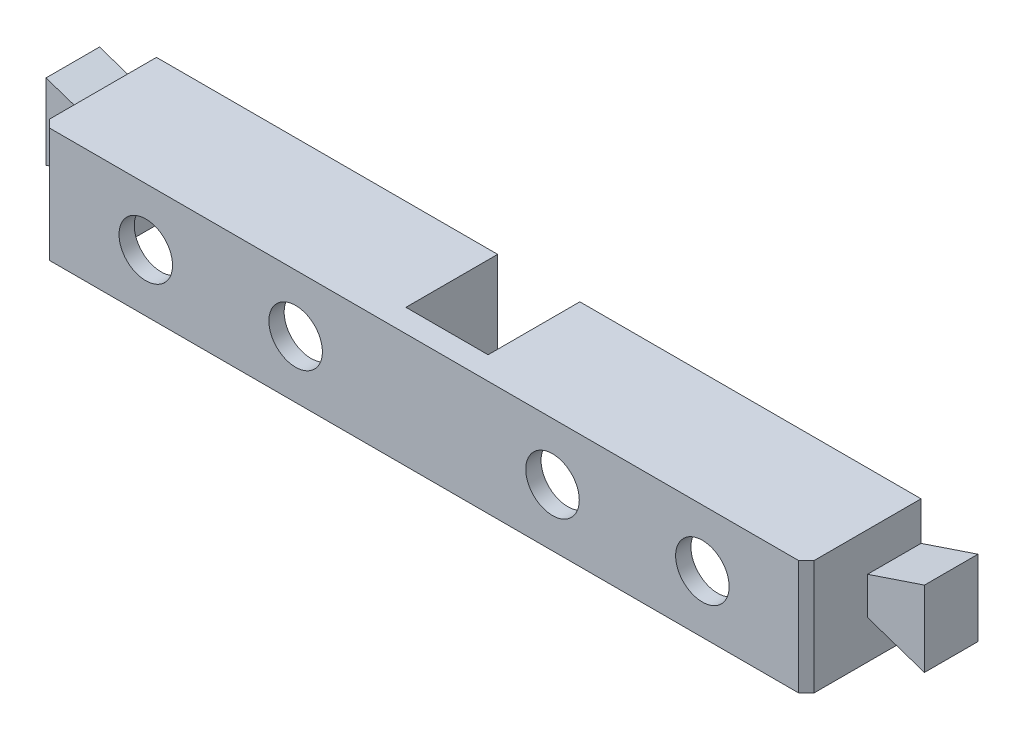
from build123d import *

# Parameters (mm, degrees)
SKETCH1_W           = 100
SKETCH1_H           = 15
BODY_DEPTH          = 15
CLICK_DEPTH         = 7
CLICK_CHAMFER_SIZE  = 1
SKETCH3_W           = 92
SKETCH3_H           = 13
CUT_EXTRUDE1_DEPTH  = 13
SKETCH4_R           = 3.5
CUT_EXTRUDE2_DEPTH  = 13
SKETCH5_W           = 10.75
SKETCH5_H           = 12
CUT_EXTRUDE3_DEPTH  = 10
SKETCH6_W           = 10.75
SKETCH6_H           = 13
BOSS_EXTRUDE1_DEPTH = 1
SKETCH7_W           = 2
SKETCH7_H           = 13
BOSS_EXTRUDE2_DEPTH = 13
SKETCH8_W           = 2
SKETCH8_H           = 5
BOSS_EXTRUDE3_DEPTH = 13


with BuildPart() as part:
    # Sketch1 → Body (new body)
    with BuildSketch(Plane.XY):
        Rectangle(SKETCH1_W, SKETCH1_H)
    extrude(amount=BODY_DEPTH)

    # Sketch2 → Click (add)
    with BuildSketch(Plane.XY):
        Polygon((-50, 0), (-50, 2.45), (-57.45, 4.95), (-57.45, 0), (-57.45, -4.95), (-50, -2.45), align=None)
        Polygon((57.45, 0), (57.45, -4.95), (50, -2.45), (50, 0), (50, 2.45), (57.45, 4.95), align=None)
    extrude(amount=CLICK_DEPTH)

    # Click Chamfer
    click_chamfer_edges = [part.edges().sort_by_distance(p)[0] for p in [
        (-50, 0, 15),
        (50, 0, 15),
    ]]
    chamfer(click_chamfer_edges, length=CLICK_CHAMFER_SIZE)

    # Sketch3 → Cut-Extrude1 (cut)
    with BuildSketch(Plane.XZ.offset(7.5)):
        with Locations((0, 6.5)):
            Rectangle(SKETCH3_W, SKETCH3_H)
    extrude(amount=-CUT_EXTRUDE1_DEPTH, mode=Mode.SUBTRACT)

    # Sketch4 → Cut-Extrude2 (cut)
    with BuildSketch(Plane.XY.offset(15)):
        with Locations((-16.8, 0)):
            Circle(SKETCH4_R)
        with Locations((-36.4, 0)):
            Circle(SKETCH4_R)
        with Locations((16.8, 0)):
            Circle(SKETCH4_R)
        with Locations((36.4, 0)):
            Circle(SKETCH4_R)
    extrude(amount=-CUT_EXTRUDE2_DEPTH, mode=Mode.SUBTRACT)

    # Sketch5 → Cut-Extrude3 (cut)
    with BuildSketch(Plane(origin=(0, 7.5, 0), x_dir=(1, 0, 0), z_dir=(0, 1, 0))):
        with Locations((0, -6)):
            Rectangle(SKETCH5_W, SKETCH5_H)
    extrude(amount=-CUT_EXTRUDE3_DEPTH, mode=Mode.SUBTRACT)

    # Sketch6 → Boss-Extrude1 (add)
    with BuildSketch(Plane(origin=(0, 0, 13), x_dir=(-1, 0, 0), z_dir=(0, 0, -1))):
        with Locations((0, -1)):
            Rectangle(SKETCH6_W, SKETCH6_H)
    extrude(amount=BOSS_EXTRUDE1_DEPTH)

    # Sketch7 → Boss-Extrude2 (add)
    with BuildSketch(Plane(origin=(0, 0, 13), x_dir=(-1, 0, 0), z_dir=(0, 0, -1))):
        with Locations((6.375, -1)):
            Rectangle(SKETCH7_W, SKETCH7_H)
    extrude(amount=BOSS_EXTRUDE2_DEPTH)

    # Sketch8 → Boss-Extrude3 (add)
    with BuildSketch(Plane(origin=(0, 0, 13), x_dir=(-1, 0, 0), z_dir=(0, 0, -1))):
        with Locations((-6.375, 3)):
            Rectangle(SKETCH8_W, SKETCH8_H)
    extrude(amount=BOSS_EXTRUDE3_DEPTH)


solid = part.part
